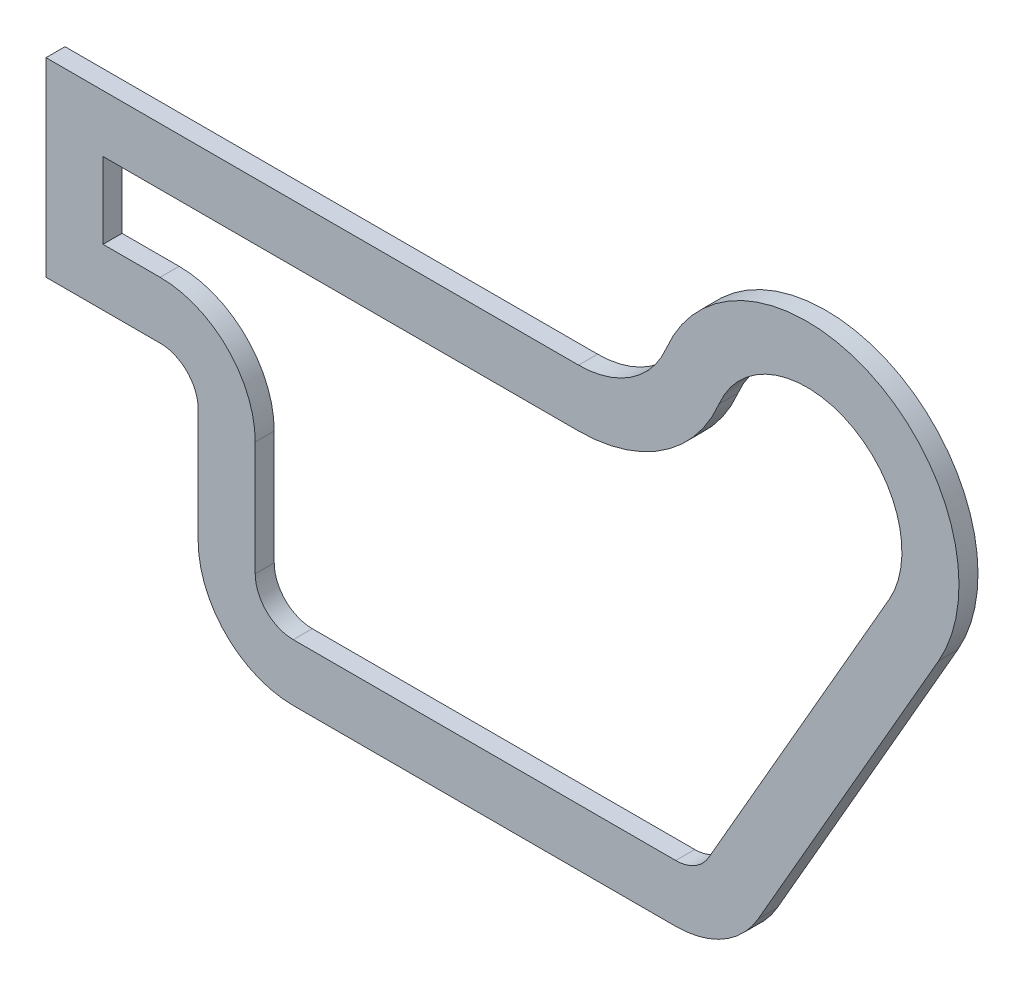
from build123d import *

# Parameters (mm, degrees)
BOSS_EXTRUDE1_DEPTH = 5
SHELL1_T            = -15


with BuildPart() as part:
    # Sketch3 → Boss-Extrude1 (new body)
    with BuildSketch(Plane.XY):
        with BuildLine():
            Line((140, 115), (0, 115))
            Line((0, 115), (0, 65))
            Line((0, 65), (30, 65))
            ThreePointArc((30, 65), (37.071067812, 62.071067812), (40, 55))
            Line((40, 55), (40, 25))
            ThreePointArc((40, 25), (47.32233047, 7.32233047), (65, 0))
            Line((65, 0), (165.538941775, 0))
            ThreePointArc((165.538941775, 0), (178.05666204, 3.359605379), (187.210014279, 12.535465651))
            Line((187.210014279, 12.535465651), (234.673716006, 95.056745042))
            ThreePointArc((234.673716006, 95.056745042), (217.699703722, 150.870886358), (163.076923077, 130.384615385))
            ThreePointArc((163.076923077, 130.384615385), (153.867504906, 119.198742642), (140, 115))
        make_face()
    extrude(amount=BOSS_EXTRUDE1_DEPTH)

    # Shell1
    shell1_openings = [part.faces().sort_by_distance(p)[0] for p in [
        (98.657145907, 64.238067092, 5),
        (98.657145907, 64.238067092, 0),
    ]]
    offset(amount=SHELL1_T, openings=shell1_openings, kind=Kind.INTERSECTION)


solid = part.part
